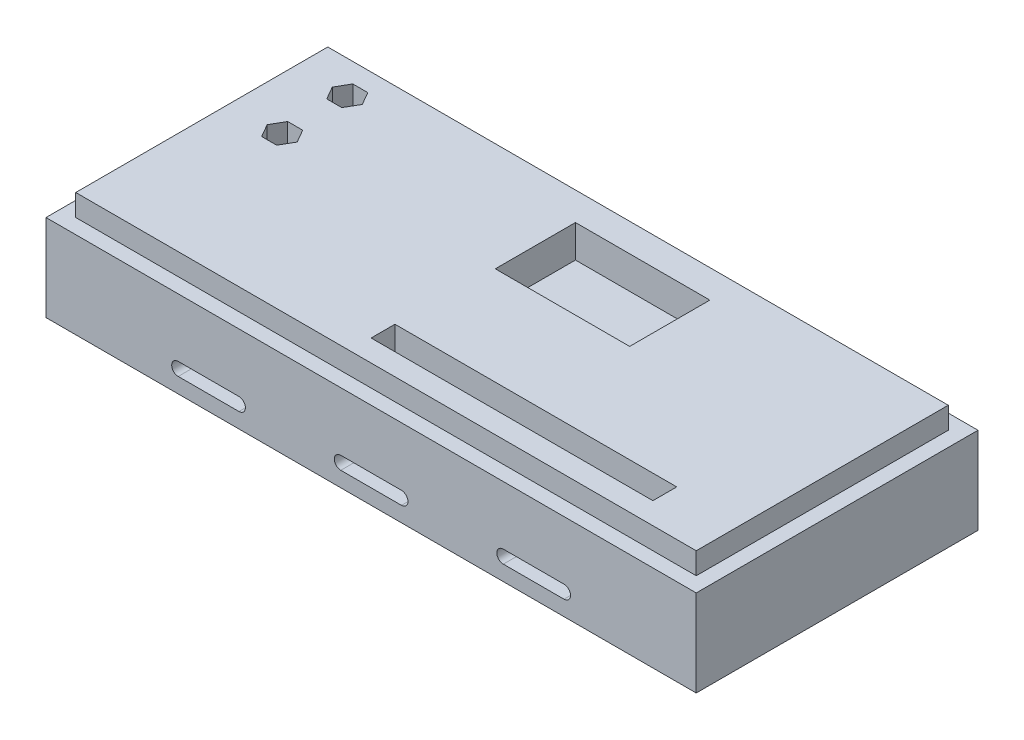
from build123d import *

# Parameters (mm, degrees)
SKETCH1_W           = 150
SKETCH1_H           = 65
BOSS_EXTRUDE1_DEPTH = 20
CUT_EXTRUDE1_DEPTH  = 66
SKETCH3_W           = 143.142
SKETCH3_H           = 58.142
BOSS_EXTRUDE2_DEPTH = 5
CUT_EXTRUDE2_DEPTH  = 6.5
SKETCH6_W           = 65
SKETCH6_H           = 5.5
CUT_EXTRUDE3_DEPTH  = 10
SKETCH7_W           = 31
SKETCH7_H           = 18.5
CUT_EXTRUDE4_DEPTH  = 7.5


with BuildPart() as part:
    # Sketch1 → Boss-Extrude1 (new body)
    with BuildSketch(Plane(origin=(0, 0, 0), x_dir=(1, 0, 0), z_dir=(0, 1, 0))):
        Rectangle(SKETCH1_W, SKETCH1_H)
    extrude(amount=BOSS_EXTRUDE1_DEPTH)

    # Sketch2 → Cut-Extrude1 (cut, through all)
    with BuildSketch(Plane.XY.offset(32.5)):
        with BuildLine():
            Line((-7, 6.5), (7, 6.5))
            ThreePointArc((7, 6.5), (8.5, 5), (7, 3.5))
            Line((7, 3.5), (-7, 3.5))
            ThreePointArc((-7, 3.5), (-8.5, 5), (-7, 6.5))
        make_face()
        with BuildLine():
            Line((-44.5, 6.5), (-30.5, 6.5))
            ThreePointArc((-30.5, 6.5), (-29, 5), (-30.5, 3.5))
            Line((-30.5, 3.5), (-44.5, 3.5))
            ThreePointArc((-44.5, 3.5), (-46, 5), (-44.5, 6.5))
        make_face()
        with BuildLine():
            Line((30.5, 6.5), (44.5, 6.5))
            ThreePointArc((44.5, 6.5), (46, 5), (44.5, 3.5))
            Line((44.5, 3.5), (30.5, 3.5))
            ThreePointArc((30.5, 3.5), (29, 5), (30.5, 6.5))
        make_face()
    extrude(amount=-CUT_EXTRUDE1_DEPTH, mode=Mode.SUBTRACT)

    # Sketch3 → Boss-Extrude2 (add)
    with BuildSketch(Plane(origin=(0, 20, 0), x_dir=(1, 0, 0), z_dir=(0, 1, 0))):
        Rectangle(SKETCH3_W, SKETCH3_H)
    extrude(amount=BOSS_EXTRUDE2_DEPTH)

    # Sketch4 → Cut-Extrude2 (cut)
    with BuildSketch(Plane(origin=(0, 25, 0), x_dir=(1, 0, 0), z_dir=(0, 1, 0))):
        Polygon((-61.303050808, 24.571), (-63.035101615, 21.571), (-61.303050808, 18.571), (-57.838949192, 18.571), (-56.106898385, 21.571), (-57.838949192, 24.571), align=None)
        Polygon((-61.303050808, 9.551), (-63.035101615, 6.551), (-61.303050808, 3.551), (-57.838949192, 3.551), (-56.106898385, 6.551), (-57.838949192, 9.551), align=None)
    extrude(amount=-CUT_EXTRUDE2_DEPTH, mode=Mode.SUBTRACT)

    # Sketch6 → Cut-Extrude3 (cut)
    with BuildSketch(Plane(origin=(0, 25, 0), x_dir=(1, 0, 0), z_dir=(0, 1, 0))):
        with Locations((24.071, -21.321)):
            Rectangle(SKETCH6_W, SKETCH6_H)
    extrude(amount=-CUT_EXTRUDE3_DEPTH, mode=Mode.SUBTRACT)

    # Sketch7 → Cut-Extrude4 (cut)
    with BuildSketch(Plane(origin=(0, 25, 0), x_dir=(1, 0, 0), z_dir=(0, 1, 0))):
        with Locations((7.571, 13.321)):
            Rectangle(SKETCH7_W, SKETCH7_H)
    extrude(amount=-CUT_EXTRUDE4_DEPTH, mode=Mode.SUBTRACT)


solid = part.part
